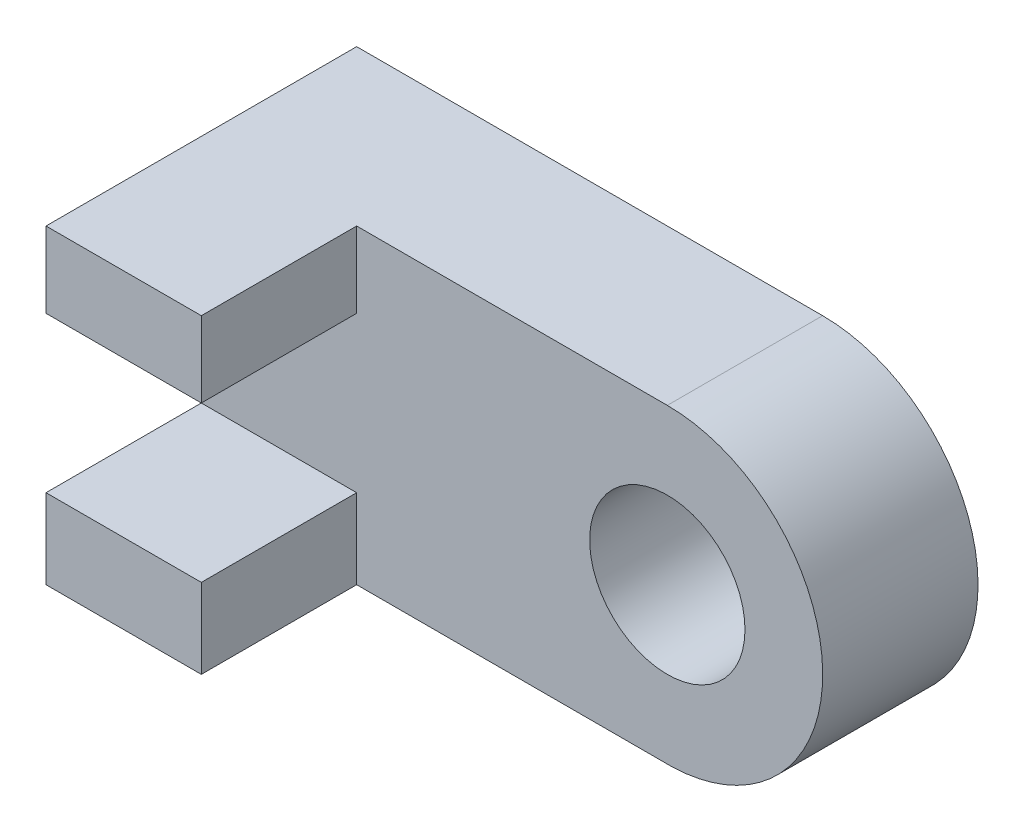
from build123d import *

# Parameters (mm, degrees)
EXTRUDE1_DEPTH     = 50.8
SKETCH3_W          = 50.8
SKETCH3_H          = 101.6
EXTRUDE2_DEPTH     = 50.8
SKETCH5_W          = 50.8
SKETCH5_H          = 50.8
CUT_EXTRUDE1_DEPTH = 50.8
SKETCH6_R          = 25.4
CUT_EXTRUDE2_DEPTH = 51.8


with BuildPart() as part:
    # Sketch2 → Extrude1 (new body)
    with BuildSketch(Plane.XY):
        with BuildLine():
            Line((-68.510209021, 50.129277125), (33.089790979, 50.129277125))
            ThreePointArc((33.089790979, 50.129277125), (83.897074784, 0.175115288), (34.810357915, -51.470722875))
            Line((34.810357915, -51.470722875), (-68.510209021, -51.470722875))
            Line((-68.510209021, -51.470722875), (-68.510209021, 50.129277125))
        make_face()
    extrude(amount=EXTRUDE1_DEPTH)

    # Sketch3 → Extrude2 (add)
    with BuildSketch(Plane.ZY.offset(68.510209021)):
        with Locations((76.2, -0.670722875)):
            Rectangle(SKETCH3_W, SKETCH3_H)
        with Locations((25.4, -0.670722875)):
            Rectangle(SKETCH3_W, SKETCH3_H)
    extrude(amount=EXTRUDE2_DEPTH)

    # Sketch5 → Cut-Extrude1 (cut)
    with BuildSketch(Plane(origin=(-68.510209021, 0, 0), x_dir=(0, 0, -1), z_dir=(1, 0, 0))):
        with Locations((-76.2, -0.005051238)):
            Rectangle(SKETCH5_W, SKETCH5_H)
    extrude(amount=-CUT_EXTRUDE1_DEPTH, mode=Mode.SUBTRACT)

    # Sketch6 → Cut-Extrude2 (cut, through all)
    with BuildSketch(Plane.XY.offset(50.8)):
        with Locations((33.089790979, -0.685291529)):
            Circle(SKETCH6_R)
    extrude(amount=-CUT_EXTRUDE2_DEPTH, mode=Mode.SUBTRACT)


solid = part.part
